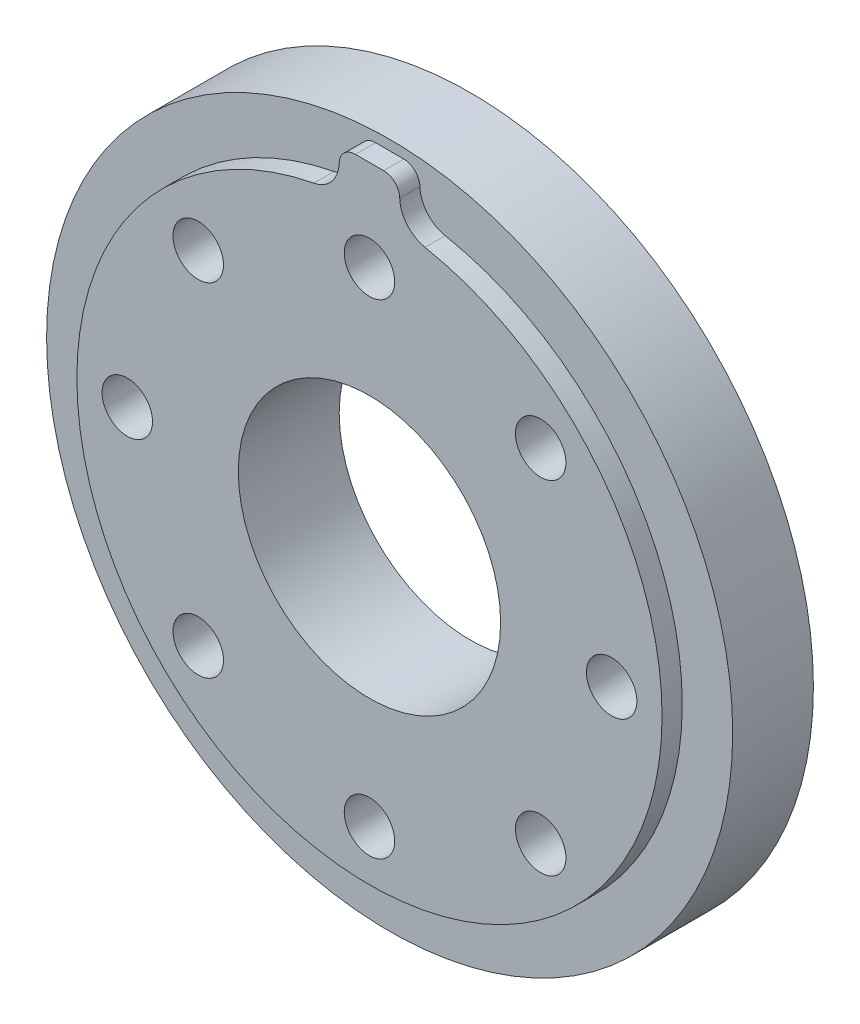
from build123d import *

# Parameters (mm, degrees)
SKETCH_1_R               = 17
EXTRUDE_1_DEPTH          = 4
EXTRUDE_2_DEPTH          = 1
FILLET_1_R               = 1.55
FILLET_2_R               = 0.8
SKETCH_3_R               = 6.5
CUT_EXTRUDE_1_DEPTH      = 6
SKETCH_4_R               = 1.25
CUT_EXTRUDE_2_DEPTH      = 6.0000001
PATTERN_CIRCULAR_1_COUNT = 2
PATTERN_CIRCULAR_1_ANGLE = 45


with BuildPart() as part:
    # ｽｹｯﾁ1 → ﾎﾞｽ - 押し出し1 (new body)
    with BuildSketch(Plane.XY):
        Circle(SKETCH_1_R)
    extrude(amount=EXTRUDE_1_DEPTH)

    # ｽｹｯﾁ2 → ﾎﾞｽ - 押し出し2 (add)
    with BuildSketch(Plane.XY.offset(4)):
        with BuildLine():
            Line((-1.5, 14.422205102), (-1.5, 12.5))
            Line((-1.5, 12.5), (1.5, 12.5))
            Line((1.5, 12.5), (1.5, 14.422205102))
            ThreePointArc((1.5, 14.422205102), (0, 14.5), (-1.5, 14.422205102))
        make_face()
        with BuildLine():
            Line((1.5, 12.5), (-1.5, 12.5))
            Line((-1.5, 12.5), (-1.5, 14.422205102))
            ThreePointArc((-1.5, 14.422205102), (-9.708243919, -10.770329614), (14.5, 0))
            ThreePointArc((14.5, 0), (10.770329614, 9.708243919), (1.5, 14.422205102))
            Line((1.5, 14.422205102), (1.5, 12.5))
        make_face()
        with BuildLine():
            Line((-1.5, 16.5), (-1.5, 14.422205102))
            ThreePointArc((-1.5, 14.422205102), (0, 14.5), (1.5, 14.422205102))
            Line((1.5, 14.422205102), (1.5, 16.5))
            Line((1.5, 16.5), (-1.5, 16.5))
        make_face()
    extrude(amount=EXTRUDE_2_DEPTH)

    # ﾌｨﾚｯﾄ1
    fillet_1_edges = [part.edges().sort_by_distance(p)[0] for p in [
        (-1.5, 14.422205102, 4.5),
        (1.5, 14.422205102, 4.5),
    ]]
    fillet(fillet_1_edges, radius=FILLET_1_R)

    # ﾌｨﾚｯﾄ2
    fillet_2_edges = [part.edges().sort_by_distance(p)[0] for p in [
        (1.5, 16.5, 4.5),
        (-1.5, 16.5, 4.5),
    ]]
    fillet(fillet_2_edges, radius=FILLET_2_R)

    # ｽｹｯﾁ3 → ｶｯﾄ - 押し出し1 (cut, through all)
    with BuildSketch(Plane.XY.offset(5)):
        Circle(SKETCH_3_R)
    extrude(amount=-CUT_EXTRUDE_1_DEPTH, mode=Mode.SUBTRACT)

    # ｽｹｯﾁ4 → ｶｯﾄ - 押し出し2 (cut, through all)
    with BuildSketch(Plane(origin=(0, 0, 0), x_dir=(-1, 0, 0), z_dir=(0, 0, -1))):
        with Locations((0, 12)):
            Circle(SKETCH_4_R)
        with Locations((12, 0)):
            Circle(SKETCH_4_R)
        with Locations((0, -12)):
            Circle(SKETCH_4_R)
        with Locations((-12, 0)):
            Circle(SKETCH_4_R)
    cut_extrude_2 = extrude(amount=-CUT_EXTRUDE_2_DEPTH, mode=Mode.SUBTRACT)

    # 円形ﾊﾟﾀｰﾝ1: ｶｯﾄ - 押し出し2 ×2 about axis
    pattern_circular_1_axis = Axis((0, 0, 0), (0, 0, 1))
    for i in range(1, PATTERN_CIRCULAR_1_COUNT):
        add(cut_extrude_2.rotate(pattern_circular_1_axis, i * PATTERN_CIRCULAR_1_ANGLE / (PATTERN_CIRCULAR_1_COUNT - 1)), mode=Mode.SUBTRACT)


solid = part.part
